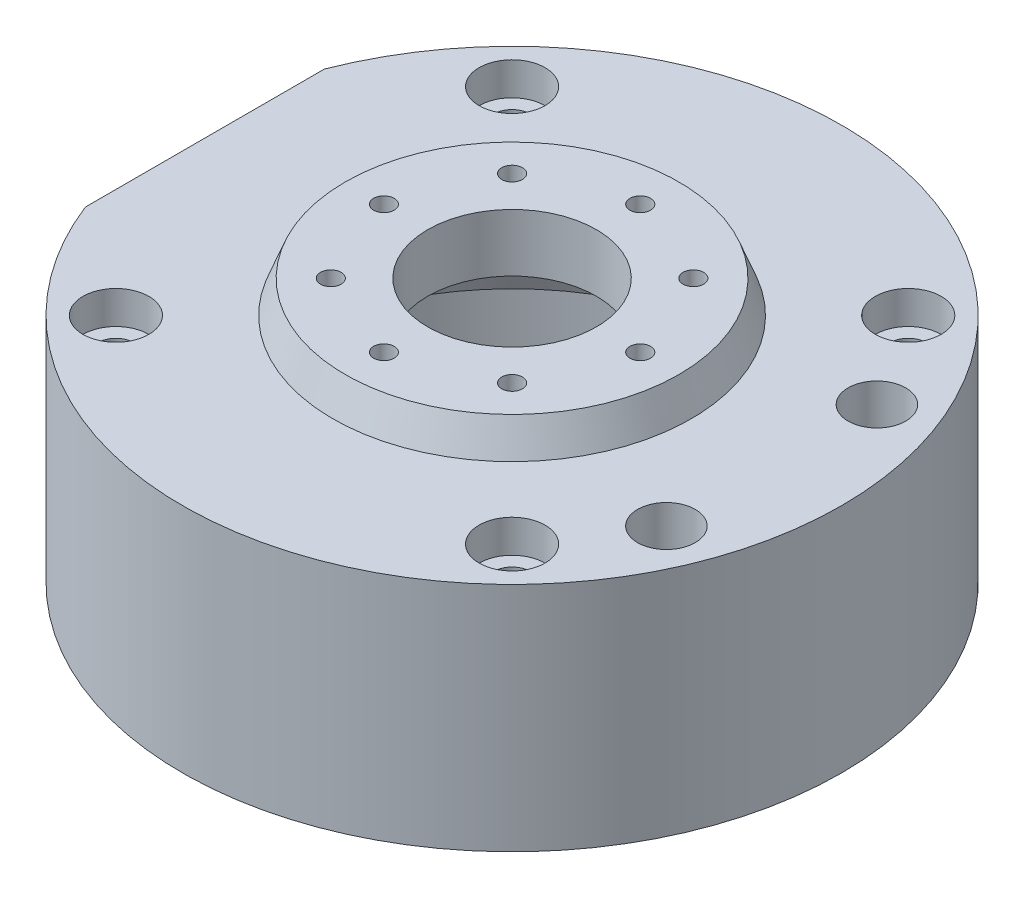
from build123d import *

# Parameters (mm, degrees)
CBORE_FOR_M4_SHCS1_D           = 4.5
CBORE_FOR_M4_SHCS1_CBORE_D     = 8
CBORE_FOR_M4_SHCS1_CBORE_DEPTH = 4
M3X0_5_TAPPED_HOLE1_D          = 2.5
M8X1_0_TAPPED_HOLE1_D          = 7
M8X1_0_TAPPED_HOLE1_DEPTH      = 21
M8X1_0_TAPPED_HOLE1_TIP        = 2.103012167
HOLE1_D                        = 4.4
HOLE1_CBORE_D                  = 7.85
HOLE1_CBORE_DEPTH              = 1.27
CUT_EXTRUDE1_DEPTH             = 1
CUT_EXTRUDE1_DEPTH_BACK        = 33
CUT_EXTRUDE2_REACH             = 79.279
M3X0_5_TAPPED_HOLE2_D          = 2.5
M3X0_5_TAPPED_HOLE2_DEPTH      = 7.5
M3X0_5_TAPPED_HOLE2_TIP        = 0.751075774


with BuildPart() as part:
    # Sketch1 → Revolve1 (revolve)
    with BuildSketch(Plane.XY):
        Polygon((10.235, 32), (10.235, 25), (25, 25), (29.55, 10), (29.55, 0), (40, 0), (40, 28.1), (21.75, 28.1), (20.25, 32), align=None)
    revolve(axis=Axis((0, 10.573566085, 0), (0, -1, 0)))

    # CBORE for M4 SHCS1 (through all)
    with Locations(Plane(origin=(0, 28.1, 0), x_dir=(1, 0, 0), z_dir=(0, 1, 0))):
        with Locations((-24.04163056, 24.04163056), (24.04163056, 24.04163056), (24.04163056, -24.04163056), (-24.04163056, -24.04163056)):
            CounterBoreHole(CBORE_FOR_M4_SHCS1_D / 2, CBORE_FOR_M4_SHCS1_CBORE_D / 2, CBORE_FOR_M4_SHCS1_CBORE_DEPTH)

    # M3x0.5 Tapped Hole1 (through all)
    with Locations(Plane(origin=(0, 32, 0), x_dir=(1, 0, 0), z_dir=(0, 1, 0))):
        with Locations((-11, 11), (11, 11), (11, -11), (-11, -11), (0, 15.556349186), (15.556349186, 0), (0, -15.556349186), (-15.556349186, 0)):
            Hole(M3X0_5_TAPPED_HOLE1_D / 2)

    # M8x1.0 Tapped Hole1
    with Locations(Plane(origin=(0, 28.1, 0), x_dir=(1, 0, 0), z_dir=(0, 1, 0))):
        with Locations((31.508719031, 12.775), (31.508719031, -12.775)):
            Hole(M8X1_0_TAPPED_HOLE1_D / 2, depth=M8X1_0_TAPPED_HOLE1_DEPTH)
            with Locations((0, 0, -(M8X1_0_TAPPED_HOLE1_DEPTH + M8X1_0_TAPPED_HOLE1_TIP / 2))):  # 118° drill point
                Cone(0, M8X1_0_TAPPED_HOLE1_D / 2, M8X1_0_TAPPED_HOLE1_TIP, mode=Mode.SUBTRACT)

    # Hole1 (through all)
    with Locations(Plane(origin=(0, 0, 0), x_dir=(-1, 0, 0), z_dir=(0, -1, 0))):
        with Locations((-31.508719031, -12.775), (-31.508719031, 12.775)):
            CounterBoreHole(HOLE1_D / 2, HOLE1_CBORE_D / 2, HOLE1_CBORE_DEPTH)

    # Sketch13 → Cut-Extrude1 (cut, two sides)
    with BuildSketch(Plane.XZ) as cut_extrude1_sk:
        with BuildLine():
            Line((-37.279350853, 14.5), (-37.279350853, -14.5))
            ThreePointArc((-37.279350853, -14.5), (-40, 0), (-37.279350853, 14.5))
        make_face()
    extrude(amount=CUT_EXTRUDE1_DEPTH, mode=Mode.SUBTRACT)
    extrude(cut_extrude1_sk.sketch, amount=-CUT_EXTRUDE1_DEPTH_BACK, mode=Mode.SUBTRACT)

    # Sketch14 → Cut-Extrude2 (cut, up to next)
    with BuildSketch(Plane.ZY.offset(37.279350853), mode=Mode.PRIVATE) as cut_extrude2_sk1:
        with BuildLine():
            Line((-7, 7.358571571), (-7, 0))
            Line((-7, 0), (7, 0))
            Line((7, 0), (7, 7.358571571))
            ThreePointArc((7, 7.358571571), (0, 24.5), (-7, 7.358571571))
        make_face()
    cut_extrude2_tool1 = extrude(cut_extrude2_sk1.sketch, amount=-CUT_EXTRUDE2_REACH, mode=Mode.PRIVATE) & part.part
    add(cut_extrude2_tool1.solids().sort_by_distance((-37.279351, 12.225831, 0))[0], mode=Mode.SUBTRACT)

    # M3x0.5 Tapped Hole2
    with Locations(Plane.ZY.offset(37.279350853)):
        with Locations((-11, 25.5), (-11, 3.5), (11, 3.5), (11, 25.5)):
            Hole(M3X0_5_TAPPED_HOLE2_D / 2, depth=M3X0_5_TAPPED_HOLE2_DEPTH)
            with Locations((0, 0, -(M3X0_5_TAPPED_HOLE2_DEPTH + M3X0_5_TAPPED_HOLE2_TIP / 2))):  # 118° drill point
                Cone(0, M3X0_5_TAPPED_HOLE2_D / 2, M3X0_5_TAPPED_HOLE2_TIP, mode=Mode.SUBTRACT)


solid = part.part
